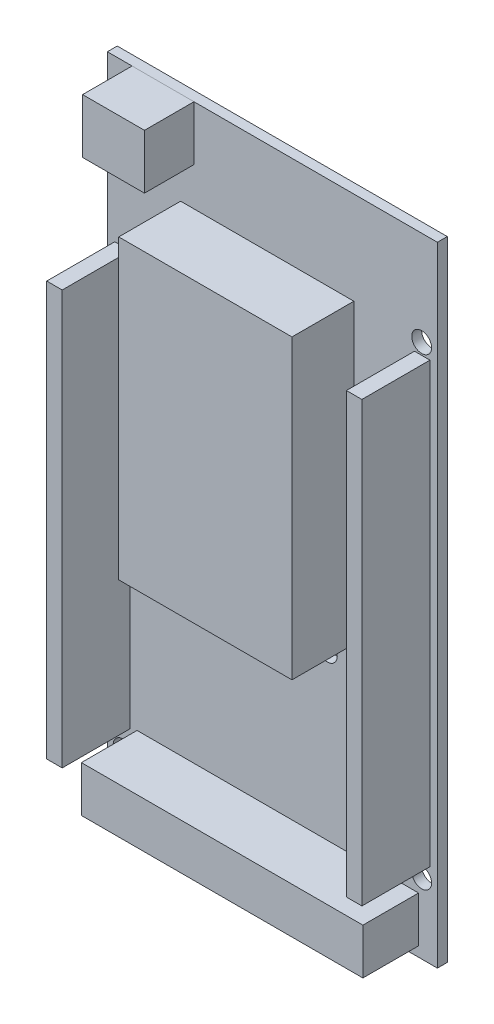
from build123d import *

# Parameters (mm, degrees)
SKETCH_1_W                  = 53.34
SKETCH_1_H                  = 101.6
EXTRUDE_1_DEPTH             = 1.6
SKETCH_2_W                  = 2.5
SKETCH_2_H                  = 66.9
SKETCH_2_H_2                = 70.9
EXTRUDE_2_DEPTH             = 11
SKETCH_3_W                  = 45.5
SKETCH_3_H                  = 7.4
EXTRUDE_3_DEPTH             = 9
HOLE_WIZARD_3_2_3_2_1_D     = 3.2
HOLE_WIZARD_3_2_3_2_1_DEPTH = 1.6
SKETCH_7_W                  = 28
SKETCH_7_H                  = 48
EXTRUDE_4_DEPTH             = 10
SKETCH_8_W                  = 10
SKETCH_8_H                  = 8.8
EXTRUDE_5_DEPTH             = 8


with BuildPart() as part:
    # 草圖1 → 填料-伸長1 (new body)
    with BuildSketch(Plane.XY):
        Rectangle(SKETCH_1_W, SKETCH_1_H)
    extrude(amount=EXTRUDE_1_DEPTH)

    # 草圖2 → 填料-伸長2 (add)
    with BuildSketch(Plane.XY.offset(1.6)):
        with Locations((-24.22, -8.65)):
            Rectangle(SKETCH_2_W, SKETCH_2_H)
        with Locations((24.22, -1.75)):
            Rectangle(SKETCH_2_W, SKETCH_2_H_2)
    extrude(amount=EXTRUDE_2_DEPTH)

    # 草圖3 → 填料-伸長3 (add)
    with BuildSketch(Plane.XY.offset(1.6)):
        with Locations((0.88, -45.5)):
            Rectangle(SKETCH_3_W, SKETCH_3_H)
    extrude(amount=EXTRUDE_3_DEPTH)

    # Ø3.2 (3.2) 直徑孔1
    with Locations(Plane.XY.offset(1.6)):
        with Locations((24.13, -39.37), (-24.13, -45.72), (-19.05, -15.24), (8.89, -15.24), (-24.13, 36.83), (24.13, 35.56)):
            Hole(HOLE_WIZARD_3_2_3_2_1_D / 2, depth=HOLE_WIZARD_3_2_3_2_1_DEPTH)

    # 草圖7 → 填料-伸長4 (add)
    with BuildSketch(Plane.XY.offset(1.6)):
        with Locations((-0.83, 11.8)):
            Rectangle(SKETCH_7_W, SKETCH_7_H)
    extrude(amount=EXTRUDE_4_DEPTH)


with BuildPart() as body_2:
    # 草圖8 → 填料-伸長5 (new body)
    with BuildSketch(Plane.XY.offset(1.6)):
        with Locations((-17.67, 46.4)):
            Rectangle(SKETCH_8_W, SKETCH_8_H)
    extrude(amount=EXTRUDE_5_DEPTH)


solid = Compound([part.part, body_2.part])
